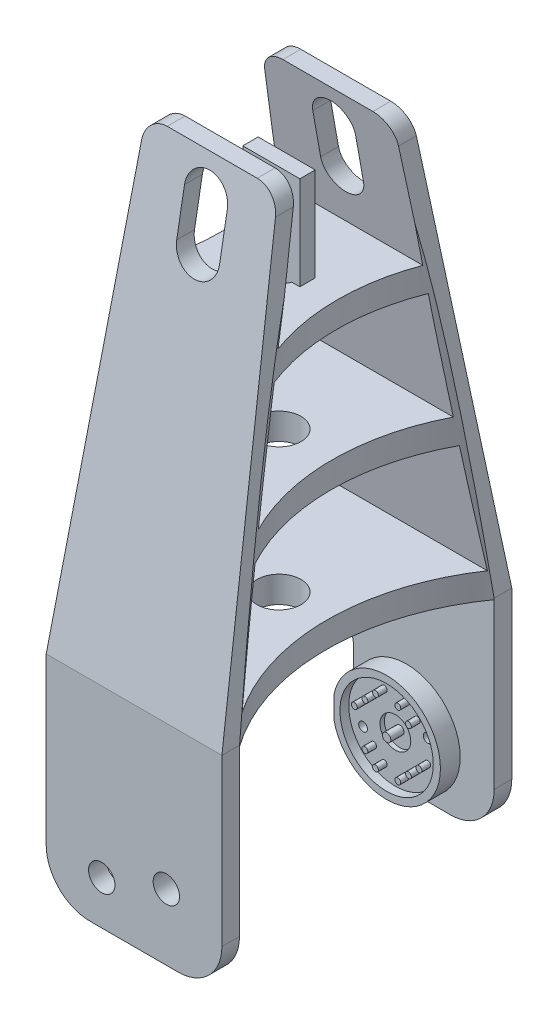
from build123d import *

# Parameters (mm, degrees)
BOSS_EXTRUDE1_DEPTH             = 20
SKETCH6_R                       = 12.25
BOSS_EXTRUDE2_DEPTH             = 4.5
SKETCH4_W                       = 157.727290237
SKETCH4_H                       = 50
CUT_EXTRUDE10_DEPTH             = 34.640665044
CUT_EXTRUDE12_DEPTH             = 141.625104537
CUT_EXTRUDE12_DEPTH_BACK        = 141.625104537
SKETCH11_R                      = 10.625
SKETCH11_R_2                    = 0.95
SKETCH11_R_3                    = 0.675
CUT_EXTRUDE13_DEPTH             = 2
SKETCH12_R                      = 3.5
SKETCH12_R_2                    = 0.95
CUT_EXTRUDE14_DEPTH             = 1
CUT_EXTRUDE15_REACH             = 153.797
SKETCH14_R                      = 5
CUT_EXTRUDE16_DEPTH             = 124.889930448
CUT_EXTRUDE17_DEPTH             = 108.475579093
CUT_EXTRUDE17_DRAFT             = -2.1
CUT_EXTRUDE17_PROFILE_2_DEPTH   = 108.475579093
CUT_EXTRUDE17_PROFILE_2_DRAFT   = -2.1
CUT_EXTRUDE18_REACH             = 151.086
SKETCH16_R                      = 1
SKETCH18_R                      = 6.25
BOSS_EXTRUDE4_DEPTH             = 5.5
BOSS_EXTRUDE4_DEPTH_BACK        = 4
SKETCH19_W                      = 13
SKETCH19_H                      = 3.5
BOSS_EXTRUDE5_DEPTH             = 21.3
BOSS_EXTRUDE5_DIRECTION_2_REACH = 125.89
SKETCH20_R                      = 7.5
BOSS_EXTRUDE6_DEPTH             = 0.75
CUT_EXTRUDE19_REACH             = 153.797
SKETCH17_R                      = 3


with BuildPart() as part:
    # Sketch1 → Boss-Extrude1 (new, symmetric)
    with BuildSketch(Plane.YZ):
        Polygon((-14.772710004, -33), (35.227289996, -33), (135.227290242, -15.19542909), (135.227290242, -11.132523186), (105.227290242, -16.473894445), (105.227290242, 16.473894445), (135.227290242, 11.132523186), (135.227290242, 15.19542909), (35.227289996, 33), (-14.772710004, 33), (-14.772710004, 29), (34.917768753, 29), (34.917768753, -29), (-14.772710004, -29), align=None)
        Polygon((40.917768753, -27.923928772), (67.072529497, -23.267185861), (67.072529497, 23.267185861), (40.917768753, 27.923928772), align=None, mode=Mode.SUBTRACT)
        Polygon((73.072529497, 22.198911609), (99.227290242, 17.542168697), (99.227290242, -17.542168697), (73.072529497, -22.198911609), align=None, mode=Mode.SUBTRACT)
    extrude(amount=BOSS_EXTRUDE1_DEPTH, both=True)

    # Sketch6 → Boss-Extrude2 (add)
    with BuildSketch(Plane.XY.offset(-29)):
        Circle(SKETCH6_R)
    extrude(amount=BOSS_EXTRUDE2_DEPTH)

    # Sketch4 → Cut-Extrude10 (cut, symmetric)
    with BuildSketch(Plane(origin=(0, 0, 0), x_dir=(0, 1, 0), z_dir=(0, 0, 1))):
        with Locations((61.363645124, 0)):
            Rectangle(SKETCH4_W, SKETCH4_H)
        with BuildLine():
            Line((35.227289996, 20), (130.476978326, 15.237515595))
            ThreePointArc((130.476978326, 15.237515595), (133.850026805, 13.689879231), (135.227290242, 10.243753901))
            Line((135.227290242, 10.243753901), (135.227290242, -10.243753901))
            ThreePointArc((135.227290242, -10.243753901), (133.850026805, -13.689879231), (130.476978326, -15.237515595))
            Line((130.476978326, -15.237515595), (35.227289996, -20))
            Line((35.227289996, -20), (-2.499999995, -20))
            ThreePointArc((-2.499999995, -20), (-9.571067807, -17.071067812), (-12.499999995, -10))
            Line((-12.499999995, -10), (-12.499999995, 10))
            ThreePointArc((-12.499999995, 10), (-9.571067807, 17.071067812), (-2.499999995, 20))
            Line((-2.499999995, 20), (35.227289996, 20))
        make_face(mode=Mode.SUBTRACT)
    extrude(amount=CUT_EXTRUDE10_DEPTH, both=True, mode=Mode.SUBTRACT)

    # Sketch8 → Cut-Extrude12 (cut, two sides)
    with BuildSketch(Plane(origin=(0, 0, 0), x_dir=(0, 1, 0), z_dir=(0, 0, 1))) as cut_extrude12_sk:
        with BuildLine():
            Line((117.127290242, 4.875), (127.127290242, 4.875))
            ThreePointArc((127.127290242, 4.875), (132.002290242, 0), (127.127290242, -4.875))
            Line((127.127290242, -4.875), (117.127290242, -4.875))
            ThreePointArc((117.127290242, -4.875), (112.252290242, 0), (117.127290242, 4.875))
        make_face()
    extrude(amount=CUT_EXTRUDE12_DEPTH, mode=Mode.SUBTRACT)
    extrude(cut_extrude12_sk.sketch, amount=-CUT_EXTRUDE12_DEPTH_BACK, mode=Mode.SUBTRACT)

    # Sketch11 → Cut-Extrude13 (cut)
    with BuildSketch(Plane.XY.offset(-24.5)):
        Circle(SKETCH11_R)
        Circle(SKETCH11_R_2, mode=Mode.SUBTRACT)
        with Locations(Location((2.545584412, 7.353910524, 0), (0, 0, 180))):
            Circle(SKETCH11_R_3, mode=Mode.SUBTRACT)
        with Locations(Location((4.949747468, 4.949747468, 0), (0, 0, 180))):
            Circle(SKETCH11_R_3, mode=Mode.SUBTRACT)
        with Locations((-2.545584412, 7.353910524)):
            Circle(SKETCH11_R_3, mode=Mode.SUBTRACT)
        with Locations((-4.949747468, 4.949747468)):
            Circle(SKETCH11_R_3, mode=Mode.SUBTRACT)
        with Locations(Location((-7.353910524, 2.545584412, 0), (0, 0, 180))):
            Circle(SKETCH11_R_3, mode=Mode.SUBTRACT)
        with Locations(Location((-4.949747468, -4.949747468, 0), (0, 0, 180))):
            Circle(SKETCH11_R_3, mode=Mode.SUBTRACT)
        with Locations(Location((-2.545584412, -7.353910524, 0), (0, 0, 180))):
            Circle(SKETCH11_R_3, mode=Mode.SUBTRACT)
        with Locations(Location((7.353910524, -2.545584412, 0), (0, 0, 180))):
            Circle(SKETCH11_R_3, mode=Mode.SUBTRACT)
        with Locations((2.545584412, -7.353910524)):
            Circle(SKETCH11_R_3, mode=Mode.SUBTRACT)
        with Locations((4.949747468, -4.949747468)):
            Circle(SKETCH11_R_3, mode=Mode.SUBTRACT)
    extrude(amount=-CUT_EXTRUDE13_DEPTH, mode=Mode.SUBTRACT)

    # Sketch12 → Cut-Extrude14 (cut)
    with BuildSketch(Plane.XY.offset(-26.5)):
        Circle(SKETCH12_R)
        Circle(SKETCH12_R_2, mode=Mode.SUBTRACT)
    extrude(amount=-CUT_EXTRUDE14_DEPTH, mode=Mode.SUBTRACT)

    # Sketch13 → Cut-Extrude15 (cut, up to next)
    with BuildSketch(Plane(origin=(0, 0, -33), x_dir=(1, 0, 0), z_dir=(0, 0, -1)), mode=Mode.PRIVATE) as cut_extrude15_sk1:
        with BuildLine():
            Line((-9, 12.499999995), (-20, 12.499999995))
            Line((-20, 12.499999995), (-20, -21.500000005))
            ThreePointArc((-20, -21.500000005), (-19.160251472, -18.726499024), (-16.923076923, -16.88461539))
            ThreePointArc((-16.923076923, -16.88461539), (-13.343597645, -13.937601575), (-12, -9.500000005))
            Line((-12, -9.500000005), (-12, 9.499999995))
            ThreePointArc((-12, 9.499999995), (-11.121320344, 11.621320339), (-9, 12.499999995))
        make_face()
    cut_extrude15_tool1 = extrude(cut_extrude15_sk1.sketch, amount=-CUT_EXTRUDE15_REACH, mode=Mode.PRIVATE) & part.part
    add(cut_extrude15_tool1.solids().sort_by_distance((-16.130851, 1.777121, -33))[0], mode=Mode.SUBTRACT)

    # Sketch14 → Cut-Extrude16 (cut, through all)
    with BuildSketch(Plane(origin=(0, 105.227290242, 0), x_dir=(-1, 0, 0), z_dir=(0, 1, 0))):
        with Locations(Location((0, 0, 0), (0, 0, 90))):
            Circle(SKETCH14_R)
    extrude(amount=-CUT_EXTRUDE16_DEPTH, mode=Mode.SUBTRACT)


with BuildPart() as cut_extrude17_tool:
    # Sketch15 → Cut-Extrude17 (with draft: the straight prism first)
    with BuildSketch(Plane.XZ.offset(-34.917768753)):
        with BuildLine():
            Line((-22.502320086, 32.227030747), (-22.502320086, -32.227030747))
            ThreePointArc((-22.502320086, -32.227030747), (-10.730823709, 0), (-22.502320086, 32.227030747))
        make_face()
    extrude(amount=-CUT_EXTRUDE17_DEPTH)
    # Cut-Extrude17: the draft: its side faces are tilted about the plane it starts from
    cut_extrude17_sides = [cut_extrude17_tool.faces().sort_by_distance(p)[0] for p in [
        (-22.502320086, 89.155558299, 0),
        (-10.730823709, 89.155558299, 0),
    ]]
    draft(cut_extrude17_sides, Plane.XZ.offset(-34.917768753), CUT_EXTRUDE17_DRAFT)


with BuildPart() as part_1:
    add(part.part)

    # Cut-Extrude17: cut by cut_extrude17_tool
    add(cut_extrude17_tool.part, mode=Mode.SUBTRACT)


with BuildPart() as cut_extrude17_profile_2_tool:
    # Sketch15 → Cut-Extrude17 profile 2 (with draft: the straight prism first)
    with BuildSketch(Plane.XZ.offset(-34.917768753)):
        with BuildLine():
            ThreePointArc((22.502320086, 32.227030747), (10.730823709, 0), (22.502320086, -32.227030747))
            Line((22.502320086, -32.227030747), (22.502320086, 32.227030747))
        make_face()
    extrude(amount=-CUT_EXTRUDE17_PROFILE_2_DEPTH)
    # Cut-Extrude17 profile 2: the draft: its side faces are tilted about the plane it starts from
    cut_extrude17_profile_2_sides = [cut_extrude17_profile_2_tool.faces().sort_by_distance(p)[0] for p in [
        (22.502320086, 89.155558299, 0),
        (10.730823709, 89.155558299, 0),
    ]]
    draft(cut_extrude17_profile_2_sides, Plane.XZ.offset(-34.917768753), CUT_EXTRUDE17_PROFILE_2_DRAFT)


with BuildPart() as part_2:
    add(part_1.part)

    # Cut-Extrude17 profile 2: cut by cut_extrude17_profile_2_tool
    add(cut_extrude17_profile_2_tool.part, mode=Mode.SUBTRACT)

    # Sketch16 → Cut-Extrude18 (cut, up to next)
    with BuildSketch(Plane.XY.offset(-26.5), mode=Mode.PRIVATE) as cut_extrude18_sk1:
        with Locations((-7.353910524, -2.545584412)):
            Circle(SKETCH16_R)
    cut_extrude18_tool1 = extrude(cut_extrude18_sk1.sketch, amount=-CUT_EXTRUDE18_REACH, mode=Mode.PRIVATE) & part_2.part
    # Sketch16 → Cut-Extrude18 (cut, up to next)
    with BuildSketch(Plane.XY.offset(-26.5), mode=Mode.PRIVATE) as cut_extrude18_sk2:
        with Locations((7.353910524, 2.545584412)):
            Circle(SKETCH16_R)
    cut_extrude18_tool2 = extrude(cut_extrude18_sk2.sketch, amount=-CUT_EXTRUDE18_REACH, mode=Mode.PRIVATE) & part_2.part
    add(cut_extrude18_tool1.solids().sort_by_distance((-7.353911, -2.545584, -26.5))[0], mode=Mode.SUBTRACT)
    add(cut_extrude18_tool2.solids().sort_by_distance((7.353911, 2.545584, -26.5))[0], mode=Mode.SUBTRACT)

    # Sketch18 → Boss-Extrude4 (add, two sides)
    with BuildSketch(Plane(origin=(0, 0, 29), x_dir=(1, 0, 0), z_dir=(0, 0, -1))) as boss_extrude4_sk:
        with Locations(Location((0, 0, 0), (0, 0, 270))):
            Circle(SKETCH18_R)
    extrude(amount=BOSS_EXTRUDE4_DEPTH)
    extrude(boss_extrude4_sk.sketch, amount=-BOSS_EXTRUDE4_DEPTH_BACK)

    # Sketch19 → Boss-Extrude5 (add)
    with BuildSketch(Plane(origin=(0, 105.227290242, 0), x_dir=(-1, 0, 0), z_dir=(0, 1, 0))):
        Rectangle(SKETCH19_W, SKETCH19_H)
    extrude(amount=BOSS_EXTRUDE5_DEPTH)

    # Boss-Extrude5 direction 2: up to this face of the body (flat: up to its plane)
    boss_extrude5_direction_2_end = Plane(part_2.part.faces().sort_by_distance((0, 99.227290242, 17.061388609))[0])
    # Sketch19 → Boss-Extrude5 direction 2 (add, up to the picked face)
    with BuildSketch(Plane(origin=(0, 105.227290242, 0), x_dir=(-1, 0, 0), z_dir=(0, 1, 0)), mode=Mode.PRIVATE) as boss_extrude5_direction_2_sk1:
        Rectangle(SKETCH19_W, SKETCH19_H)
    boss_extrude5_direction_2_tool1 = split(extrude(boss_extrude5_direction_2_sk1.sketch, amount=-BOSS_EXTRUDE5_DIRECTION_2_REACH, mode=Mode.PRIVATE), bisect_by=boss_extrude5_direction_2_end, keep=Keep.BOTH, mode=Mode.PRIVATE)
    add(boss_extrude5_direction_2_tool1.solids().sort_by(Axis((0, 105.22729, 0), (0, -1, 0)))[0])

    # Sketch20 → Boss-Extrude6 (add)
    with BuildSketch(Plane(origin=(0, 0, 23.5), x_dir=(1, 0, 0), z_dir=(0, 0, -1))):
        with Locations(Location((0, 0, 0), (0, 0, 270))):
            Circle(SKETCH20_R)
    extrude(amount=-BOSS_EXTRUDE6_DEPTH)

    # Sketch17 → Cut-Extrude19 (cut, up to next)
    with BuildSketch(Plane.XY.offset(33), mode=Mode.PRIVATE) as cut_extrude19_sk1:
        with Locations((7.353910524, 2.545584412)):
            Circle(SKETCH17_R)
    cut_extrude19_tool1 = extrude(cut_extrude19_sk1.sketch, amount=-CUT_EXTRUDE19_REACH, mode=Mode.PRIVATE) & part_2.part
    # Sketch17 → Cut-Extrude19 (cut, up to next)
    with BuildSketch(Plane.XY.offset(33), mode=Mode.PRIVATE) as cut_extrude19_sk2:
        with Locations((-7.353910524, -2.545584412)):
            Circle(SKETCH17_R)
    cut_extrude19_tool2 = extrude(cut_extrude19_sk2.sketch, amount=-CUT_EXTRUDE19_REACH, mode=Mode.PRIVATE) & part_2.part
    add(cut_extrude19_tool1.solids().sort_by_distance((7.353911, 2.545584, 33))[0], mode=Mode.SUBTRACT)
    add(cut_extrude19_tool2.solids().sort_by_distance((-7.353911, -2.545584, 33))[0], mode=Mode.SUBTRACT)


solid = part_2.part
